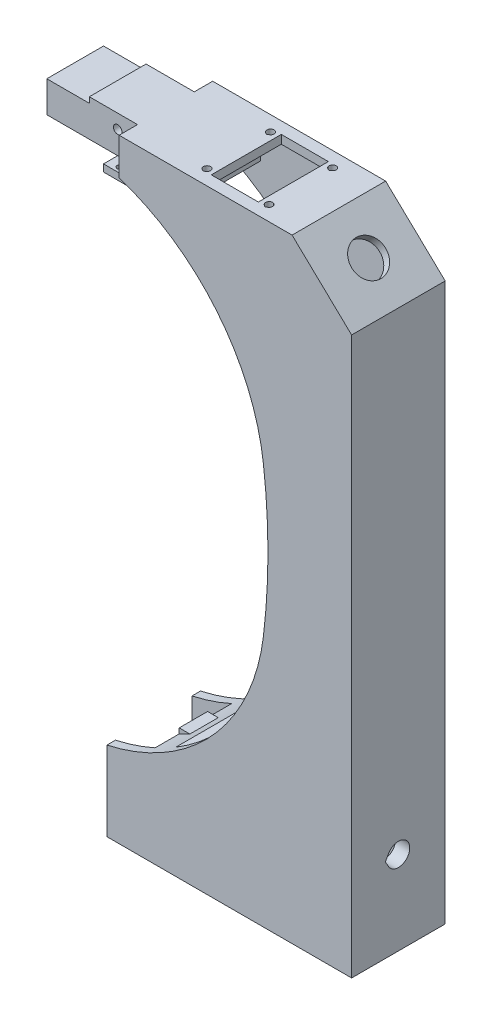
from build123d import *

# Parameters (mm, degrees)
EXTRUDE_6_DEPTH      = 33
CUT_EXTRUDE_START    = 3
CUT_EXTRUDE_2_DEPTH  = 27
EXTRUDE_START        = 6.5
SKETCH_7_W           = 32
SKETCH_7_H           = 13
EXTRUDE_7_DEPTH      = 20
EXTRUDE_START_2      = 1.5
SKETCH_11_W          = 13
SKETCH_11_H          = 2.5
EXTRUDE_15_DEPTH     = 30
CUT_EXTRUDE_START_2  = 180
CUT_EXTRUDE_3_DEPTH  = 10
SKETCH_13_R          = 1.5
CUT_EXTRUDE_4_DEPTH  = 30
SKETCH_14_W          = 15
SKETCH_14_H          = 2
CUT_EXTRUDE_5_DEPTH  = 30
EXTRUDE_START_3      = 11.5
SKETCH_15_W          = 67.299618531
SKETCH_15_H          = 10
EXTRUDE_16_DEPTH     = 10
CUT_EXTRUDE_START_3  = 17
CUT_EXTRUDE_7_DEPTH  = 75
CUT_EXTRUDE_START_4  = 13
CUT_EXTRUDE_9_DEPTH  = 5
SKETCH_20_W          = 16.6
SKETCH_20_H          = 24.7
CUT_EXTRUDE_10_DEPTH = 5
SKETCH_21_R          = 6
CUT_EXTRUDE_11_DEPTH = 5
SKETCH_22_W          = 51
SKETCH_22_H          = 47
CUT_EXTRUDE_12_DEPTH = 27


with BuildPart() as part:
    # Эскиз1 → Бобышка-Вытянуть6 (new body)
    with BuildSketch(Plane.XY):
        with BuildLine():
            Line((4.299618531, 175.402841826), (4.299618531, 188.402841826))
            Line((4.299618531, 188.402841826), (65.299618531, 188.402841826))
            Line((65.299618531, 188.402841826), (86.299618531, 168.402841826))
            Line((86.299618531, 168.402841826), (86.299619, 0))
            Line((86.299619, 0), (86.299619, -28))
            Line((86.299619, -28), (0, -28))
            Line((0, -28), (0, 0))
            ThreePointArc((0, 0), (37.229295141, 21.561020186), (55.173142182, 60.662380285))
            ThreePointArc((55.173142182, 60.662380285), (56.797307883, 87.162380285), (55.173142182, 113.662380285))
            ThreePointArc((55.173142182, 113.662380285), (38.726552267, 151.940422917), (4.299618531, 175.402841826))
        make_face()
    extrude(amount=EXTRUDE_6_DEPTH)

    # Эскиз5 → Вырез-Вытянуть2 (cut)
    with BuildSketch(Plane.XY.offset(CUT_EXTRUDE_START)):
        Polygon((24.099618531, 175.402841826), (4.299618531, 175.402841826), (4.299618531, 169.136823089), (-18.700381469, 169.136823089), (-18.700381469, -23.02337805), (14, -23.02337805), (14, 8.47662195), (81.178938205, 8.47662195), (81.178938205, 169.136823089), (64.099618531, 185.402841826), (24.099618531, 185.402841826), align=None)
    extrude(amount=CUT_EXTRUDE_2_DEPTH, mode=Mode.SUBTRACT)

    # Эскиз7 → Бобышка-Вытянуть7 (add)
    with BuildSketch(Plane.XY.offset(EXTRUDE_START)):
        with Locations((-11.700381469, 181.902841826)):
            Rectangle(SKETCH_7_W, SKETCH_7_H)
    extrude(amount=EXTRUDE_7_DEPTH)

    # Эскиз11 → Бобышка-Вытянуть15 (add)
    with BuildSketch(Plane.XY.offset(EXTRUDE_START_2)):
        with Locations((3.799618531, 174.152841826)):
            Rectangle(SKETCH_11_W, SKETCH_11_H)
    extrude(amount=EXTRUDE_15_DEPTH)

    # Эскиз12 → Вырез-Вытянуть3 (cut)
    with BuildSketch(Plane(origin=(0, 0, 0), x_dir=(1, 0, 0), z_dir=(0, 1, 0)).offset(CUT_EXTRUDE_START_2)):
        with BuildLine():
            Line((1.142696527, -30.654700538), (1.642696527, -30.366025404))
            ThreePointArc((1.642696527, -30.366025404), (1.142696527, -28.5), (0.642696527, -30.366025404))
            Line((0.642696527, -30.366025404), (1.142696527, -30.654700538))
        make_face()
        with BuildLine():
            Line((1.142696527, -4.654700538), (1.642696527, -4.366025404))
            ThreePointArc((1.642696527, -4.366025404), (1.142696527, -2.5), (0.642696527, -4.366025404))
            Line((0.642696527, -4.366025404), (1.142696527, -4.654700538))
        make_face()
    extrude(amount=-CUT_EXTRUDE_3_DEPTH, mode=Mode.SUBTRACT)

    # Эскиз13 → Вырез-Вытянуть4 (cut)
    with BuildSketch(Plane.XY):
        with Locations((-2.700381469, 183.402841826)):
            Circle(SKETCH_13_R)
    extrude(amount=CUT_EXTRUDE_4_DEPTH, mode=Mode.SUBTRACT)

    # Эскиз14 → Вырез-Вытянуть5 (cut)
    with BuildSketch(Plane.XY):
        with Locations((-20.200381469, 187.402841826)):
            Rectangle(SKETCH_14_W, SKETCH_14_H)
    extrude(amount=CUT_EXTRUDE_5_DEPTH, mode=Mode.SUBTRACT)

    # Эскиз15 → Бобышка-Вытянуть16 (add)
    with BuildSketch(Plane.XY.offset(EXTRUDE_START_3)):
        with Locations((47.649809735, 1.5)):
            Rectangle(SKETCH_15_W, SKETCH_15_H)
    extrude(amount=EXTRUDE_16_DEPTH)

    # Эскиз17 → Вырез-Вытянуть7 (cut)
    with BuildSketch(Plane(origin=(0, 0, 0), x_dir=(0, 0, -1), z_dir=(1, 0, 0)).offset(CUT_EXTRUDE_START_3)):
        with BuildLine():
            Line((-21.118802154, 1.5), (-19.964101615, 3.5))
            ThreePointArc((-19.964101615, 3.5), (-12.5, 1.5), (-19.964101615, -0.5))
            Line((-19.964101615, -0.5), (-21.118802154, 1.5))
        make_face()
    extrude(amount=CUT_EXTRUDE_7_DEPTH, mode=Mode.SUBTRACT)

    # Эскиз18 → Вырез-Вытянуть9 (cut)
    with BuildSketch(Plane(origin=(0, 0, 0), x_dir=(0, 0, -1), z_dir=(1, 0, 0)).offset(CUT_EXTRUDE_START_4)):
        with BuildLine():
            Line((-18.809401077, 1.5), (-18.232050808, 2.5))
            ThreePointArc((-18.232050808, 2.5), (-14.5, 1.5), (-18.232050808, 0.5))
            Line((-18.232050808, 0.5), (-18.809401077, 1.5))
        make_face()
    extrude(amount=CUT_EXTRUDE_9_DEPTH, mode=Mode.SUBTRACT)

    # Эскиз20 → Вырез-Вытянуть10 (cut)
    with BuildSketch(Plane(origin=(0, 188.402841826, 0), x_dir=(1, 0, 0), z_dir=(0, 1, 0))):
        with Locations((40.95, -16.5)):
            Rectangle(SKETCH_20_W, SKETCH_20_H)
        with BuildLine():
            Line((30, -29.143375673), (30.625, -28.782531755))
            ThreePointArc((30.625, -28.782531755), (30, -26.45), (29.375, -28.782531755))
            Line((29.375, -28.782531755), (30, -29.143375673))
        make_face()
        with BuildLine():
            Line((30, -6.743375673), (30.625, -6.382531755))
            ThreePointArc((30.625, -6.382531755), (30, -4.05), (29.375, -6.382531755))
            Line((29.375, -6.382531755), (30, -6.743375673))
        make_face()
        with BuildLine():
            Line((51.9, -6.743375673), (52.525, -6.382531755))
            ThreePointArc((52.525, -6.382531755), (51.9, -4.05), (51.275, -6.382531755))
            Line((51.275, -6.382531755), (51.9, -6.743375673))
        make_face()
        with BuildLine():
            Line((51.9, -29.143375673), (52.525, -28.782531755))
            ThreePointArc((52.525, -28.782531755), (51.9, -26.45), (51.275, -28.782531755))
            Line((51.275, -28.782531755), (51.9, -29.143375673))
        make_face()
    extrude(amount=-CUT_EXTRUDE_10_DEPTH, mode=Mode.SUBTRACT)

    # Эскиз21 → Вырез-Вытянуть11 (cut)
    with BuildSketch(Plane(origin=(125.147492247, 131.404866859, 0), x_dir=(0, 0, -1), z_dir=(0.6896551724137922, 0.7241379310344839, 0))):
        with Locations((-16.5, 68.147063703)):
            Circle(SKETCH_21_R)
    extrude(amount=-CUT_EXTRUDE_11_DEPTH, mode=Mode.SUBTRACT)

    # Эскиз22 → Вырез-Вытянуть12 (cut)
    with BuildSketch(Plane.XY.offset(CUT_EXTRUDE_START)):
        with Locations((55.799619, -1.5)):
            Rectangle(SKETCH_22_W, SKETCH_22_H)
    extrude(amount=CUT_EXTRUDE_12_DEPTH, mode=Mode.SUBTRACT)


solid = part.part
